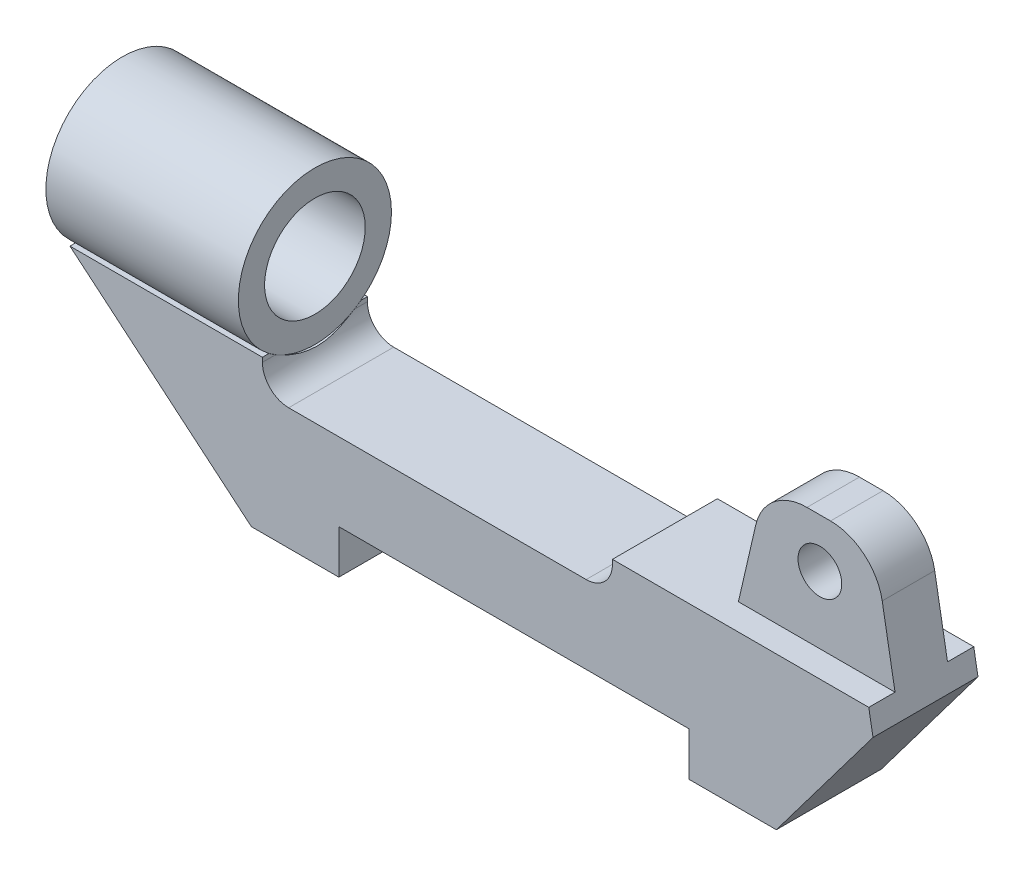
from build123d import *

# Parameters (mm, degrees)
BOSS_EXTRUDE1_DEPTH = 6
SKETCH1_3_R         = 2.5
BOSS_EXTRUDE2_DEPTH = 3
FILLET1_R           = 3
FILLET2_R           = 6
CUT_EXTRUDE1_START  = -22
SKETCH2_R           = 8.75
CUT_EXTRUDE1_DEPTH  = 22.272822
SKETCH2_5_R         = 8.75
SKETCH2_5_R_2       = 5.75
EXTRUDE_THIN4_DEPTH = 22


with BuildPart() as part:
    # Sketch1 → Boss-Extrude1 (new body, symmetric)
    with BuildSketch(Plane.XY):
        Polygon((20, 0), (30, 0), (41.045558347, 14.657951006), (40.562061127, 17.4), (22.663487489, 17.4), (11.263487489, 17.4), (11.263487489, 13.9), (-28.736512511, 13.9), (-28.736512511, 17.4), (-50.736512511, 17.4), (-30, 0), (-20, 0), (-20, 5), (20, 5), align=None)
    extrude(amount=BOSS_EXTRUDE1_DEPTH, both=True)

    # Sketch1_3 → Boss-Extrude2 (add, symmetric)
    with BuildSketch(Plane.XY):
        Polygon((22.663487489, 17.4), (40.562061127, 17.4), (38.224326656, 30.657951006), (25.724326656, 30.657951006), align=None)
        with Locations((31.974326656, 25.057951006)):
            Circle(SKETCH1_3_R, mode=Mode.SUBTRACT)
    extrude(amount=BOSS_EXTRUDE2_DEPTH, both=True)

    # Fillet1
    fillet1_edges = [part.edges().sort_by_distance(p)[0] for p in [
        (-28.736512511, 13.9, 0),
        (11.263487489, 13.9, 0),
    ]]
    fillet(fillet1_edges, radius=FILLET1_R)

    # Fillet2
    fillet2_edges = [part.edges().sort_by_distance(p)[0] for p in [
        (25.724326656, 30.657951006, 0),
        (38.224326656, 30.657951006, 0),
    ]]
    fillet(fillet2_edges, radius=FILLET2_R)

    # Sketch2 → Cut-Extrude1 (cut)
    with BuildSketch(Plane(origin=(-28.736512511, 0, 0), x_dir=(0, 0, -1), z_dir=(1, 0, 0)).offset(CUT_EXTRUDE1_START)):
        with Locations((0, 24.4)):
            Circle(SKETCH2_R)
    extrude(amount=CUT_EXTRUDE1_DEPTH, mode=Mode.SUBTRACT)


with BuildPart() as body_2:
    # Sketch2_5 → Extrude-Thin4 (new body)
    with BuildSketch(Plane(origin=(-28.736512511, 0, 0), x_dir=(0, 0, -1), z_dir=(1, 0, 0))):
        with Locations((0, 24.4)):
            Circle(SKETCH2_5_R)
        with Locations((0, 24.4)):
            Circle(SKETCH2_5_R_2, mode=Mode.SUBTRACT)
    extrude(amount=-EXTRUDE_THIN4_DEPTH)


solid = Compound([part.part, body_2.part])
